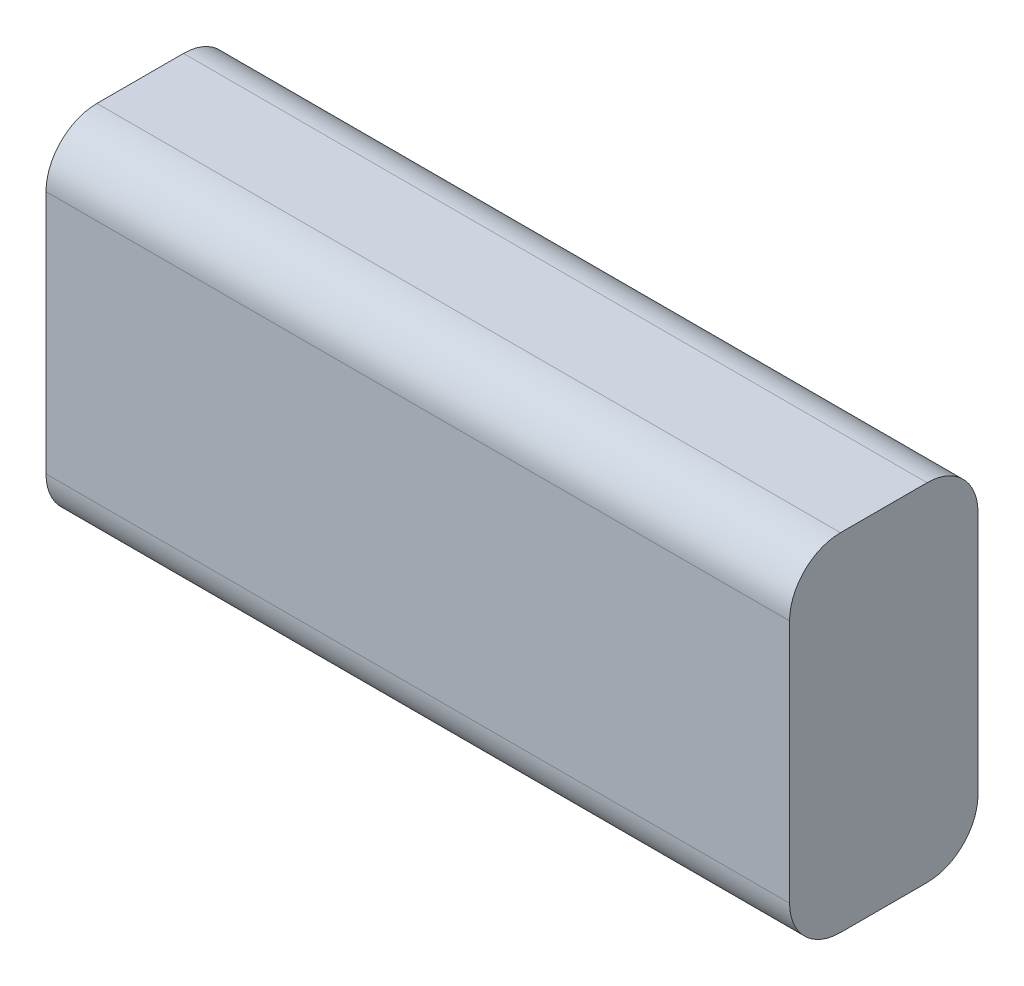
from build123d import *

# Parameters (mm, degrees)
SKETCH1_W           = 73
SKETCH1_H           = 34
BOSS_EXTRUDE1_DEPTH = 18.5
FILLET1_R           = 5


with BuildPart() as part:
    # Sketch1 → Boss-Extrude1 (new body)
    with BuildSketch(Plane.XY):
        with Locations((9.335978836, 2.068783069)):
            Rectangle(SKETCH1_W, SKETCH1_H)
    extrude(amount=BOSS_EXTRUDE1_DEPTH)

    # Fillet1
    fillet1_edges = [part.edges().sort_by_distance(p)[0] for p in [
        (9.335978836, 19.068783069, 18.5),
        (9.335978836, 19.068783069, 0),
        (9.335978836, -14.931216931, 0),
        (9.335978836, -14.931216931, 18.5),
    ]]
    fillet(fillet1_edges, radius=FILLET1_R)


solid = part.part
